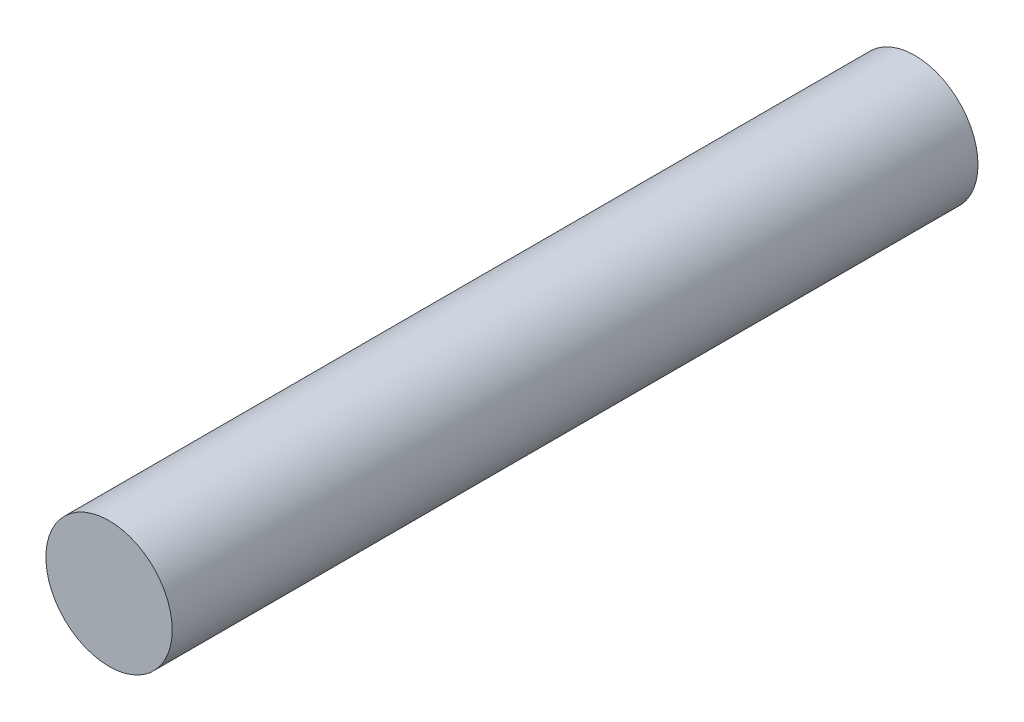
from build123d import *

# Parameters (mm, degrees)
SKETCH3_R           = 6.35
BOSS_EXTRUDE1_DEPTH = 81.02346


with BuildPart() as part:
    # Sketch3 → Boss-Extrude1 (new body)
    with BuildSketch(Plane.XY.offset(58.16346)):
        with Locations((-36.068, 0)):
            Circle(SKETCH3_R)
    extrude(amount=-BOSS_EXTRUDE1_DEPTH)


solid = part.part
